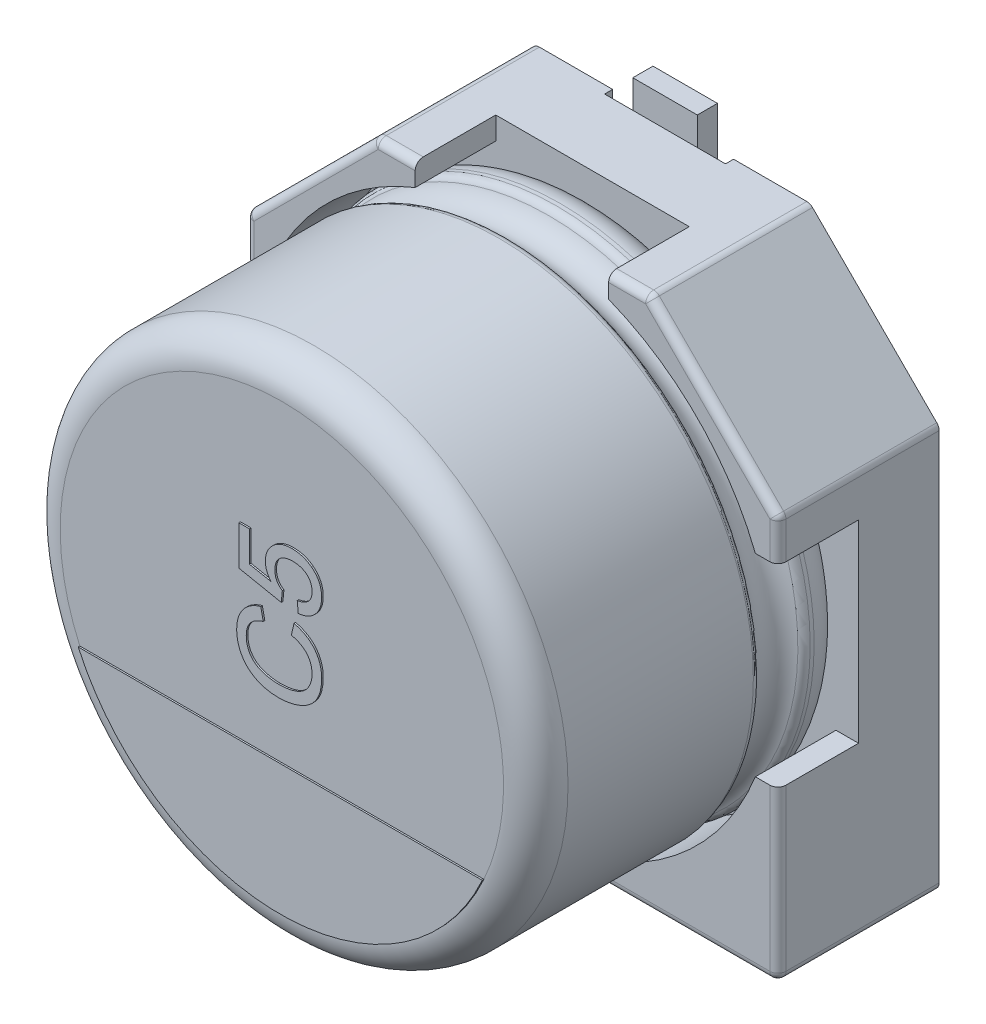
from build123d import *

# Parameters (mm, degrees)
BOSS_EXTRUDE1_DEPTH = 1
BOSS_EXTRUDE2_DEPTH = 1
SKETCH7_R           = 0.35
BOSS_EXTRUDE3_DEPTH = 0.15
SKETCH9_W           = 1.5
SKETCH9_H           = 2.35
CUT_EXTRUDE1_DEPTH  = 0.1
FILLET1_R           = 0.1
FILLET2_R           = 0.1
BOSS_EXTRUDE4_DEPTH = 0.02
TEXT_2_DEPTH        = 0.02
SKETCH19_W          = 0.8
SKETCH19_H          = 2.6
BOSS_EXTRUDE6_DEPTH = 0.25


with BuildPart() as part:
    # Sketch2 → Boss-Extrude1 (new body)
    with BuildSketch(Plane.XY):
        Polygon((-3.3, 1.7), (-1.7, 3.3), (1.7, 3.3), (3.3, 1.7), (3.3, -3.3), (-3.3, -3.3), align=None)
    extrude(amount=BOSS_EXTRUDE1_DEPTH)

    # Sketch4 → Boss-Extrude2 (add)
    with BuildSketch(Plane.XY.offset(1)):
        with BuildLine():
            Line((-3.3, 1.7), (-1.7, 3.3))
            Line((-1.7, 3.3), (-1.2, 3.3))
            Line((-1.2, 3.3), (-1.2, 3.020347662))
            ThreePointArc((-1.2, 3.020347662), (-2.298097039, 2.298097039), (-3.020347662, 1.2))
            Line((-3.020347662, 1.2), (-3.3, 1.2))
            Line((-3.3, 1.2), (-3.3, 1.7))
        make_face()
        with BuildLine():
            Line((1.7, 3.3), (3.3, 1.7))
            Line((3.3, 1.7), (3.3, 1.2))
            Line((3.3, 1.2), (3.020347662, 1.2))
            ThreePointArc((3.020347662, 1.2), (2.298097039, 2.298097039), (1.2, 3.020347662))
            Line((1.2, 3.020347662), (1.2, 3.3))
            Line((1.2, 3.3), (1.7, 3.3))
        make_face()
        with BuildLine():
            Line((3.3, -1.2), (3.3, -3.3))
            Line((3.3, -3.3), (1.2, -3.3))
            Line((1.2, -3.3), (1.2, -3.020347662))
            ThreePointArc((1.2, -3.020347662), (2.298097039, -2.298097039), (3.020347662, -1.2))
            Line((3.020347662, -1.2), (3.3, -1.2))
        make_face()
        with BuildLine():
            Line((-3.3, -1.2), (-3.3, -3.3))
            Line((-3.3, -3.3), (-1.2, -3.3))
            Line((-1.2, -3.3), (-1.2, -3.020347662))
            ThreePointArc((-1.2, -3.020347662), (-2.298097039, -2.298097039), (-3.020347662, -1.2))
            Line((-3.020347662, -1.2), (-3.3, -1.2))
        make_face()
    extrude(amount=BOSS_EXTRUDE2_DEPTH)

    # Sketch7 → Boss-Extrude3 (add)
    with BuildSketch(Plane(origin=(0, 0, 0), x_dir=(1, 0, 0), z_dir=(0, 0, -1))):
        with Locations((-2.232271432, 1.911844843)):
            Circle(SKETCH7_R)
        with Locations((2.232271432, 1.911844843)):
            Circle(SKETCH7_R)
        with Locations((-2.232271432, -1.911844843)):
            Circle(SKETCH7_R)
        with Locations((2.232271432, -1.911844843)):
            Circle(SKETCH7_R)
    extrude(amount=BOSS_EXTRUDE3_DEPTH)

    # Sketch9 → Cut-Extrude1 (cut)
    with BuildSketch(Plane(origin=(0, 0, 0), x_dir=(1, 0, 0), z_dir=(0, 0, -1))):
        with Locations((0, 2.125)):
            Rectangle(SKETCH9_W, SKETCH9_H)
        with Locations((0, -2.125)):
            Rectangle(SKETCH9_W, SKETCH9_H)
    extrude(amount=-CUT_EXTRUDE1_DEPTH, mode=Mode.SUBTRACT)

    # Fillet1
    fillet1_edges = [part.edges().sort_by_distance(p)[0] for p in [
        (3.3, -3.3, 1),
        (-3.3, -3.3, 1),
        (-3.3, 1.7, 1),
        (-1.7, 3.3, 1),
        (1.7, 3.3, 1),
        (3.3, 1.7, 1),
    ]]
    fillet(fillet1_edges, radius=FILLET1_R)

    # Sketch10 → Revolve1 (revolve)
    with BuildSketch(Plane(origin=(0, 0, 0), x_dir=(0, 0, -1), z_dir=(1, 0, 0))):
        with BuildLine():
            Line((-4.853626625, 0), (-1, 0))
            Line((-1, 0), (-1, 2.75))
            ThreePointArc((-1, 2.75), (-1.117157288, 3.032842712), (-1.4, 3.15))
            Line((-1.4, 3.15), (-1.449422929, 3.15))
            ThreePointArc((-1.449422929, 3.15), (-1.504479696, 3.133479053), (-1.541344666, 3.089375046))
            ThreePointArc((-1.541344666, 3.089375046), (-1.801990181, 2.917472047), (-2.062635697, 3.089375046))
            ThreePointArc((-2.062635697, 3.089375046), (-2.099500666, 3.133479053), (-2.154557434, 3.15))
            Line((-2.154557434, 3.15), (-4.453626625, 3.15))
            ThreePointArc((-4.453626625, 3.15), (-4.736469337, 3.032842712), (-4.853626625, 2.75))
            Line((-4.853626625, 2.75), (-4.853626625, 0))
        make_face()
    revolve(axis=Axis((0, 0, -18.9630778), (0, 0, 1)))

    # Fillet2
    fillet2_edges = [part.edges().sort_by_distance(p)[0] for p in [
        (2.2, -3.3, 2),
        (3.270710678, -3.270710678, 2),
        (3.3, 1.429289322, 2),
        (3.292387953, 1.696846987, 2),
        (1.429289322, 3.3, 2),
        (1.696846987, 3.292387953, 2),
        (-1.429289322, 3.3, 2),
        (-1.696846987, 3.292387953, 2),
        (-2.5, 2.5, 2),
        (-3.292387953, 1.696846987, 2),
        (-3.3, -2.2, 2),
        (-3.270710678, -3.270710678, 2),
        (3.3, -2.2, 2),
        (2.5, 2.5, 2),
        (-3.3, 1.429289322, 2),
        (-2.2, -3.3, 2),
    ]]
    fillet(fillet2_edges, radius=FILLET2_R)

    # Sketch13 → Boss-Extrude4 (add)
    with BuildSketch(Plane.XY.offset(4.853626625)):
        with BuildLine():
            Line((-2.506238836, -1.131930607), (2.506238836, -1.131930607))
            ThreePointArc((2.506238836, -1.131930607), (0, -2.75), (-2.506238836, -1.131930607))
        make_face()
    extrude(amount=BOSS_EXTRUDE4_DEPTH)

    # Sketch15 → Text 2 (add)
    with BuildSketch(Plane.XY.offset(4.853626625)):
        with BuildLine():
            Line((0.137389622, 0.316593633), (0.171139963, 0.461473149))
            add(Edge.make_bspline(
                [(0.171139963, 0.461473149), (0.184719205, 0.457843617), (0.211281888, 0.450743802), (0.249294555, 0.436704736), (0.284973396, 0.420954535), (0.318198658, 0.403080099), (0.348825876, 0.383025378), (0.37700883, 0.360877976), (0.402792333, 0.336641169), (0.425858287, 0.31012897), (0.446489175, 0.282031663), (0.464171898, 0.252152583), (0.479591278, 0.221021834), (0.491950748, 0.188130242), (0.501325327, 0.153719305), (0.508136304, 0.117874786), (0.512336792, 0.080509598), (0.512889354, 0.055039538), (0.513170865, 0.042063415)],
                knots=[0, 0, 0, 0, 1.145367768, 2.240481511, 3.299486216, 4.322926322, 5.312543435, 6.280301985, 7.2416403, 8.192823262, 9.141388579, 10.079393599, 11.019812878, 11.970222822, 12.938950422, 13.923894909, 14.942295558, 16, 16, 16, 16], degree=3))
            add(Edge.make_bspline(
                [(0.513170865, 0.042063415), (0.512974968, 0.028750287), (0.512591712, 0.002704216), (0.509548347, -0.035461334), (0.50408886, -0.071710574), (0.497105361, -0.106172698), (0.487517876, -0.138603304), (0.476080502, -0.169237106), (0.462232577, -0.197809744), (0.446522059, -0.224623591), (0.428664346, -0.249552903), (0.409152567, -0.273167676), (0.387446592, -0.294893809), (0.364059715, -0.315274756), (0.338683214, -0.333866555), (0.311661899, -0.351353217), (0.282519639, -0.366881226), (0.251796737, -0.381026037), (0.219790643, -0.393441241), (0.187133568, -0.404424353), (0.153760439, -0.413403647), (0.119952084, -0.421134241), (0.085424029, -0.426750142), (0.050435341, -0.431208994), (0.014771509, -0.433660561), (-0.009201459, -0.433983161), (-0.021278143, -0.434145675)],
                knots=[0, 0, 0, 0, 1.180680974, 2.309907975, 3.39230657, 4.430402719, 5.425739985, 6.38846843, 7.327253855, 8.238163682, 9.141319901, 10.044148192, 10.951882972, 11.861898394, 12.79276478, 13.739539846, 14.714057202, 15.718574761, 16.737652364, 17.7573291, 18.772768038, 19.801551793, 20.831755737, 21.873891013, 22.928945814, 24, 24, 24, 24], degree=3))
            add(Edge.make_bspline(
                [(-0.021278143, -0.434145675), (-0.034315397, -0.4339132), (-0.060073717, -0.433453889), (-0.098081116, -0.430862244), (-0.134761949, -0.426098769), (-0.17014477, -0.419495443), (-0.204305873, -0.411082573), (-0.23725329, -0.400840529), (-0.268852986, -0.388622281), (-0.299113504, -0.374745627), (-0.327665253, -0.358785546), (-0.354762577, -0.3416054), (-0.379878011, -0.322520006), (-0.403474105, -0.302187934), (-0.425149261, -0.280085417), (-0.444954877, -0.256284136), (-0.463070995, -0.230988325), (-0.479329594, -0.204201975), (-0.493595656, -0.176275134), (-0.506302564, -0.147622628), (-0.516717602, -0.118130488), (-0.525377287, -0.088032537), (-0.532271201, -0.057263976), (-0.536881183, -0.025752912), (-0.539885404, 0.006471539), (-0.540292549, 0.02819978), (-0.540498339, 0.039182288)],
                knots=[0, 0, 0, 0, 1.185610122, 2.34246615, 3.46204209, 4.547238403, 5.613845268, 6.659506797, 7.682407252, 8.692734231, 9.683951048, 10.654680354, 11.607833779, 12.549673105, 13.484816388, 14.419272854, 15.362680812, 16.31159957, 17.265732262, 18.21261905, 19.159670199, 20.10733745, 21.059306249, 22.024427552, 23.00144979, 24, 24, 24, 24], degree=3))
            add(Edge.make_bspline(
                [(-0.540498339, 0.039182288), (-0.54027585, 0.051472155), (-0.539838527, 0.075629106), (-0.53596558, 0.111030265), (-0.53016218, 0.145076857), (-0.521400985, 0.17750367), (-0.510653256, 0.208616176), (-0.496791219, 0.237924274), (-0.481084534, 0.266024209), (-0.462639265, 0.292395393), (-0.442059798, 0.317116672), (-0.419396701, 0.339965227), (-0.394799964, 0.360899322), (-0.368077184, 0.379659831), (-0.339408707, 0.396504218), (-0.308850674, 0.411613497), (-0.276208278, 0.424627676), (-0.253468798, 0.431587541), (-0.241890133, 0.435131419)],
                knots=[0, 0, 0, 0, 1.098215313, 2.158650937, 3.179873416, 4.182349117, 5.157851008, 6.118027029, 7.076341197, 8.032298369, 8.990121974, 9.948357669, 10.905435138, 11.873450097, 12.863034414, 13.874936208, 14.917943528, 16, 16, 16, 16], degree=3))
            Line((-0.241890133, 0.435131419), (-0.210815123, 0.290251903))
            add(Edge.make_bspline(
                [(-0.210815123, 0.290251903), (-0.21970095, 0.287406696), (-0.237093262, 0.281837744), (-0.261880399, 0.271949526), (-0.284890959, 0.26127058), (-0.305968529, 0.249546525), (-0.325118157, 0.236751953), (-0.342572578, 0.223181488), (-0.358006003, 0.208509995), (-0.371774287, 0.193035906), (-0.383503548, 0.176359634), (-0.393897604, 0.158872143), (-0.402497099, 0.140204709), (-0.409770496, 0.120625878), (-0.415306335, 0.099952647), (-0.419201016, 0.078269202), (-0.421455067, 0.05555649), (-0.421789822, 0.040079052), (-0.421960554, 0.032185266)],
                knots=[0, 0, 0, 0, 1.235697765, 2.418642872, 3.532555292, 4.594392283, 5.610119701, 6.580908344, 7.519430642, 8.427315627, 9.319973334, 10.216139639, 11.118687699, 12.038725643, 12.980015607, 13.949697744, 14.954307006, 16, 16, 16, 16], degree=3))
            add(Edge.make_bspline(
                [(-0.421960554, 0.032185266), (-0.42182894, 0.023122531), (-0.421570094, 0.005298806), (-0.418741414, -0.020887312), (-0.414566199, -0.046031584), (-0.408336958, -0.06996279), (-0.400471327, -0.092727501), (-0.391074044, -0.1144289), (-0.379637086, -0.134923416), (-0.366527285, -0.154190234), (-0.351810113, -0.172119905), (-0.335998775, -0.188775555), (-0.319056253, -0.204115277), (-0.300881808, -0.217955028), (-0.281409051, -0.230297385), (-0.260823414, -0.241466755), (-0.238987177, -0.251110914), (-0.208358467, -0.262011565), (-0.168833348, -0.2727293), (-0.120495718, -0.282252213), (-0.071437696, -0.288256875), (-0.038444502, -0.28892902), (-0.021895528, -0.289266159)],
                knots=[0, 0, 0, 0, 0.935100075, 1.839065892, 2.715632844, 3.564034634, 4.388093667, 5.199800233, 6.00171917, 6.806945003, 7.602082793, 8.393428172, 9.17553264, 9.958694158, 10.748327009, 11.553054559, 12.374096334, 13.209545573, 14.906836637, 16.595465087, 18.292327764, 20, 20, 20, 20], degree=3))
            add(Edge.make_bspline(
                [(-0.021895528, -0.289266159), (-0.001088295, -0.28888169), (0.039347759, -0.288134525), (0.097860474, -0.280941105), (0.152411861, -0.269796756), (0.194923463, -0.256480088), (0.226325575, -0.243084208), (0.248317261, -0.232252213), (0.268667217, -0.219887416), (0.287491124, -0.206297945), (0.304734045, -0.191308606), (0.320487583, -0.175128268), (0.334903322, -0.157753307), (0.347306436, -0.138977849), (0.35831932, -0.119524584), (0.368112186, -0.099638997), (0.376394559, -0.079308568), (0.382828475, -0.058451271), (0.388388272, -0.03736), (0.392020193, -0.015802455), (0.394069935, 0.006215216), (0.39444386, 0.020999538), (0.39463308, 0.02848096)],
                knots=[0, 0, 0, 0, 2.106854985, 4.094388766, 5.961441423, 7.741458329, 8.594569961, 9.418076185, 10.222480919, 11.003619353, 11.767127393, 12.533696482, 13.289066307, 14.050325982, 14.809648647, 15.552384038, 16.294338903, 17.030544626, 17.761979889, 18.502240791, 19.242077596, 20, 20, 20, 20], degree=3))
            add(Edge.make_bspline(
                [(0.39463308, 0.02848096), (0.39444584, 0.037409013), (0.394075974, 0.055045074), (0.390838523, 0.080901779), (0.386067714, 0.105827286), (0.378705874, 0.129519626), (0.369692165, 0.152297488), (0.358576684, 0.173974247), (0.345208005, 0.194481731), (0.330029126, 0.214061155), (0.312758155, 0.232351457), (0.293534236, 0.249113535), (0.27226973, 0.264151013), (0.249305901, 0.278094539), (0.223956735, 0.289809664), (0.196977778, 0.300660635), (0.167925608, 0.309702449), (0.147714502, 0.314263574), (0.137389622, 0.316593633)],
                knots=[0, 0, 0, 0, 1.013374089, 2.001772144, 2.95501459, 3.891367103, 4.814208647, 5.733921849, 6.652182523, 7.590185968, 8.54346024, 9.504121027, 10.481158517, 11.497760682, 12.549996529, 13.647863555, 14.798406869, 16, 16, 16, 16], degree=3))
        make_face()
        with BuildLine():
            Line((0.223411834, 0.593181799), (0.210240969, 0.72489045))
            add(Edge.make_bspline(
                [(0.210240969, 0.72489045), (0.217662028, 0.726194572), (0.232097144, 0.728731293), (0.252992401, 0.733565295), (0.272404679, 0.739843288), (0.290502099, 0.746897304), (0.307093304, 0.755282192), (0.32244026, 0.764367287), (0.335998198, 0.775081301), (0.348476211, 0.786345647), (0.359471547, 0.798709129), (0.368740995, 0.812291043), (0.376828026, 0.826712445), (0.383449329, 0.842148984), (0.388295773, 0.858624316), (0.392128479, 0.875928756), (0.394059761, 0.894285128), (0.39443953, 0.906809556), (0.39463308, 0.913192661)],
                knots=[0, 0, 0, 0, 1.237781394, 2.407677316, 3.51963579, 4.58689595, 5.594855907, 6.570874, 7.510833816, 8.428091223, 9.330271693, 10.221190844, 11.124215526, 12.043132878, 12.973586933, 13.941700858, 14.950982896, 16, 16, 16, 16], degree=3))
            add(Edge.make_bspline(
                [(0.39463308, 0.913192661), (0.3944417, 0.92102246), (0.39406745, 0.936333972), (0.390968307, 0.958623449), (0.385705739, 0.979602085), (0.378874887, 0.999469002), (0.369522636, 1.017906785), (0.357976474, 1.0348608), (0.344878756, 1.050929366), (0.329303341, 1.065178349), (0.312336747, 1.07814478), (0.293819768, 1.089336872), (0.274009016, 1.098758743), (0.252909186, 1.106691008), (0.230399493, 1.112548387), (0.206599755, 1.116856967), (0.181494791, 1.119622903), (0.164287513, 1.119883375), (0.155499561, 1.120016401)],
                knots=[0, 0, 0, 0, 1.052750423, 2.05869932, 3.018624241, 3.958205853, 4.878289862, 5.789216265, 6.712947111, 7.659433357, 8.620775926, 9.5811884, 10.56329027, 11.567503128, 12.60809625, 13.686605721, 14.818523251, 16, 16, 16, 16], degree=3))
            add(Edge.make_bspline(
                [(0.155499561, 1.120016401), (0.147124757, 1.119865206), (0.130817071, 1.119570794), (0.107070368, 1.117091362), (0.084741282, 1.112908268), (0.063583705, 1.107495737), (0.043928252, 1.100035245), (0.025489938, 1.091186681), (0.008660077, 1.080346819), (-0.00708535, 1.068286757), (-0.021200492, 1.054512644), (-0.033118941, 1.038838393), (-0.043549991, 1.021878897), (-0.052008922, 1.003292573), (-0.058293589, 0.983068478), (-0.063129076, 0.961407582), (-0.065672343, 0.938085123), (-0.066118205, 0.922047105), (-0.066347197, 0.913810045)],
                knots=[0, 0, 0, 0, 1.165854935, 2.270189951, 3.319242023, 4.32700288, 5.306253956, 6.24172124, 7.169108591, 8.088047231, 8.999810445, 9.905349262, 10.822648491, 11.767237767, 12.739852311, 13.766490849, 14.852878837, 16, 16, 16, 16], degree=3))
            add(Edge.make_bspline(
                [(-0.066347197, 0.913810045), (-0.066045926, 0.903568451), (-0.065468157, 0.883927392), (-0.06065641, 0.855692551), (-0.052780332, 0.83006462), (-0.041429729, 0.807090493), (-0.027498802, 0.786633643), (-0.011552276, 0.768343678), (0.005980659, 0.751706448), (0.019200253, 0.742627461), (0.025848858, 0.738061315)],
                knots=[0, 0, 0, 0, 1.182633468, 2.268023356, 3.298275715, 4.269491976, 5.216938987, 6.149685646, 7.069410919, 8, 8, 8, 8], degree=3))
            Line((0.025848858, 0.738061315), (0.012677993, 0.606352664))
            Line((0.012677993, 0.606352664), (-0.514156609, 0.711719585))
            Line((-0.514156609, 0.711719585), (-0.514156609, 1.199041592))
            Line((-0.514156609, 1.199041592), (-0.382447958, 1.199041592))
            Line((-0.382447958, 1.199041592), (-0.382447958, 0.819350248))
            Line((-0.382447958, 0.819350248), (-0.116355325, 0.767078377))
            add(Edge.make_bspline(
                [(-0.116355325, 0.767078377), (-0.121808832, 0.774345707), (-0.132518657, 0.788617595), (-0.14654176, 0.810879182), (-0.158362302, 0.833459086), (-0.168042331, 0.856225864), (-0.175583057, 0.879360362), (-0.180822005, 0.902722977), (-0.184362794, 0.926393253), (-0.184710424, 0.942265569), (-0.184884983, 0.950235719)],
                knots=[0, 0, 0, 0, 1.093835215, 2.148119334, 3.164235237, 4.159999629, 5.123971815, 6.089888814, 7.040853737, 8, 8, 8, 8], degree=3))
            add(Edge.make_bspline(
                [(-0.184884983, 0.950235719), (-0.184613122, 0.960608272), (-0.184077764, 0.981034344), (-0.179681854, 1.011133856), (-0.172212562, 1.039910224), (-0.162176354, 1.067607243), (-0.148800156, 1.093759776), (-0.132935744, 1.118924209), (-0.113809934, 1.142592678), (-0.092160153, 1.164906161), (-0.068094439, 1.185220151), (-0.042286485, 1.203201065), (-0.014506429, 1.218068182), (0.014653573, 1.230498514), (0.04567042, 1.239886722), (0.078117966, 1.247009099), (0.112397978, 1.250817984), (0.135734837, 1.251417964), (0.14767936, 1.251725052)],
                knots=[0, 0, 0, 0, 0.99184379, 1.95318097, 2.901668786, 3.831684196, 4.764819115, 5.705879134, 6.672196848, 7.669818607, 8.675456628, 9.680130933, 10.672473775, 11.683959944, 12.707147321, 13.767588937, 14.857383263, 16, 16, 16, 16], degree=3))
            add(Edge.make_bspline(
                [(0.14767936, 1.251725052), (0.159076386, 1.251491849), (0.181588765, 1.251031207), (0.214764917, 1.247256149), (0.246732751, 1.241037639), (0.277586934, 1.23271277), (0.307152236, 1.221464755), (0.335524158, 1.207821965), (0.36299875, 1.192084241), (0.37993525, 1.179463404), (0.388459237, 1.173111451)],
                knots=[0, 0, 0, 0, 1.059692978, 2.093196008, 3.100373587, 4.086253034, 5.061402885, 6.037282833, 7.012182238, 8, 8, 8, 8], degree=3))
            add(Edge.make_bspline(
                [(0.388459237, 1.173111451), (0.398407566, 1.165040503), (0.417976997, 1.149164082), (0.44340804, 1.121691386), (0.464920924, 1.092064746), (0.482819959, 1.060457617), (0.49653916, 1.026474701), (0.506016391, 0.990295087), (0.512286706, 0.952030668), (0.51287209, 0.925771781), (0.513170865, 0.912369482)],
                knots=[0, 0, 0, 0, 1.023063757, 2.01247625, 2.982117532, 3.944599247, 4.908953799, 5.902627458, 6.929519989, 8, 8, 8, 8], degree=3))
            add(Edge.make_bspline(
                [(0.513170865, 0.912369482), (0.512946009, 0.901314245), (0.512506147, 0.879687983), (0.5087007, 0.848018732), (0.502588826, 0.817914774), (0.493966122, 0.789261523), (0.482550414, 0.762319055), (0.468955441, 0.736703938), (0.452590601, 0.712885762), (0.434142295, 0.690609729), (0.413454647, 0.670503344), (0.391279735, 0.652255189), (0.367205206, 0.636575627), (0.341567374, 0.623157793), (0.31436974, 0.611989422), (0.285444606, 0.603441364), (0.255070847, 0.596671673), (0.234075489, 0.594357288), (0.223411834, 0.593181799)],
                knots=[0, 0, 0, 0, 1.108915132, 2.169260591, 3.195158146, 4.188014069, 5.165918008, 6.126692062, 7.092678666, 8.060306793, 9.02401023, 9.982884032, 10.937400194, 11.901029891, 12.882656982, 13.882099599, 14.924306988, 16, 16, 16, 16], degree=3))
        make_face()
    extrude(amount=TEXT_2_DEPTH)

    # Sketch19 → Boss-Extrude6 (add)
    with BuildSketch(Plane(origin=(0, 0, 0.1), x_dir=(1, 0, 0), z_dir=(0, 0, -1))):
        with Locations((0, 2.35)):
            Rectangle(SKETCH19_W, SKETCH19_H)
        with Locations((0, -2.35)):
            Rectangle(SKETCH19_W, SKETCH19_H)
    extrude(amount=BOSS_EXTRUDE6_DEPTH)


solid = part.part
